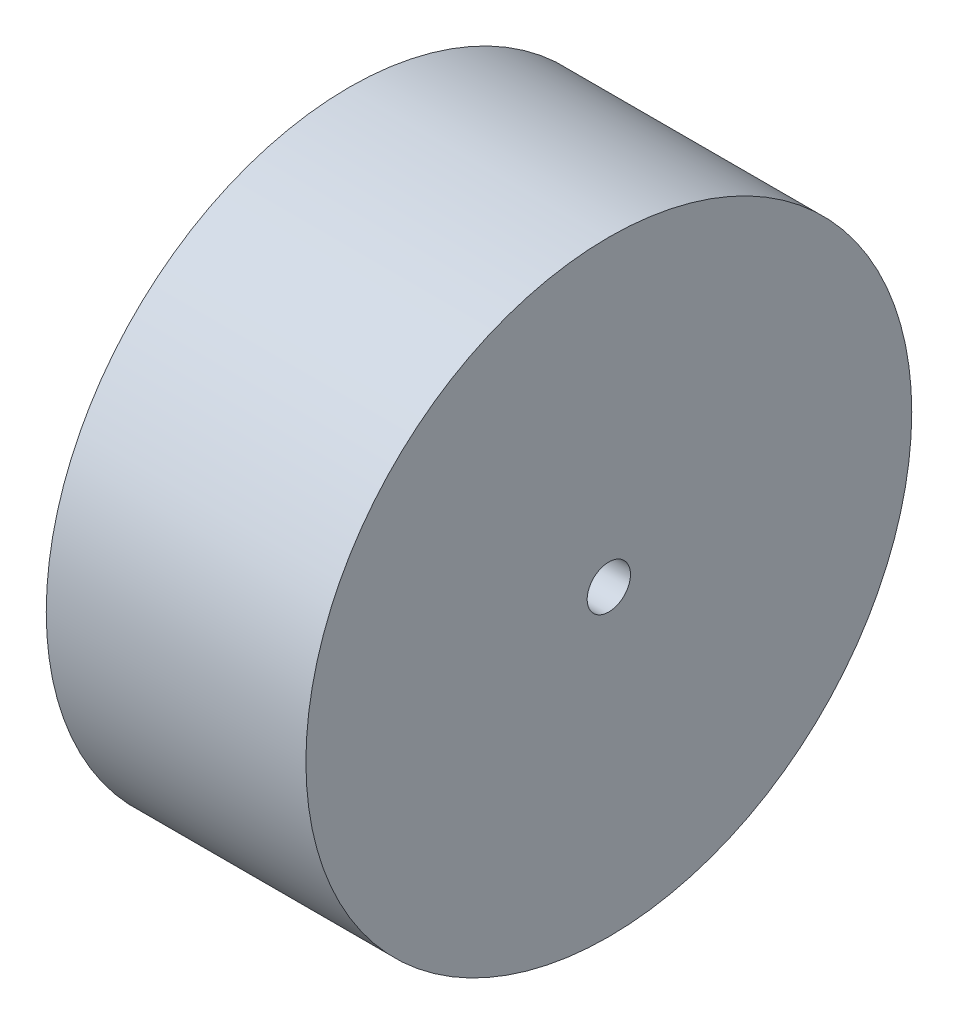
from build123d import *

# Parameters (mm, degrees)
SKETCH_1_R        = 35
SKETCH_1_R_2      = 2.5
EXTRUDE_308_DEPTH = 30


with BuildPart() as part:
    # Эскиз1 → Extrude 308 (new body)
    with BuildSketch(Plane(origin=(0, 0, 0), x_dir=(0, 0, -1), z_dir=(1, 0, 0))):
        Circle(SKETCH_1_R)
        Circle(SKETCH_1_R_2, mode=Mode.SUBTRACT)
    extrude(amount=EXTRUDE_308_DEPTH)


solid = part.part
